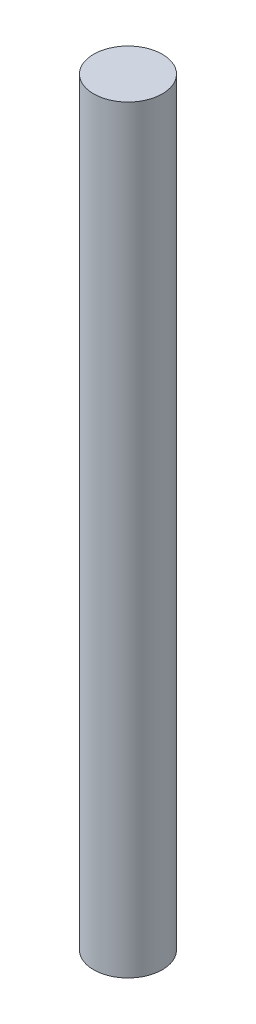
from build123d import *

# Parameters (mm, degrees)
SKETCH4_R           = 11.25
BOSS_EXTRUDE1_DEPTH = 248.5


with BuildPart() as part:
    # Sketch4 → Boss-Extrude1 (new body)
    with BuildSketch(Plane(origin=(0, 0, 0), x_dir=(1, 0, 0), z_dir=(0, 1, 0))):
        with Locations((-115.343556571, 28.368419978)):
            Circle(SKETCH4_R)
    extrude(amount=BOSS_EXTRUDE1_DEPTH)


solid = part.part
